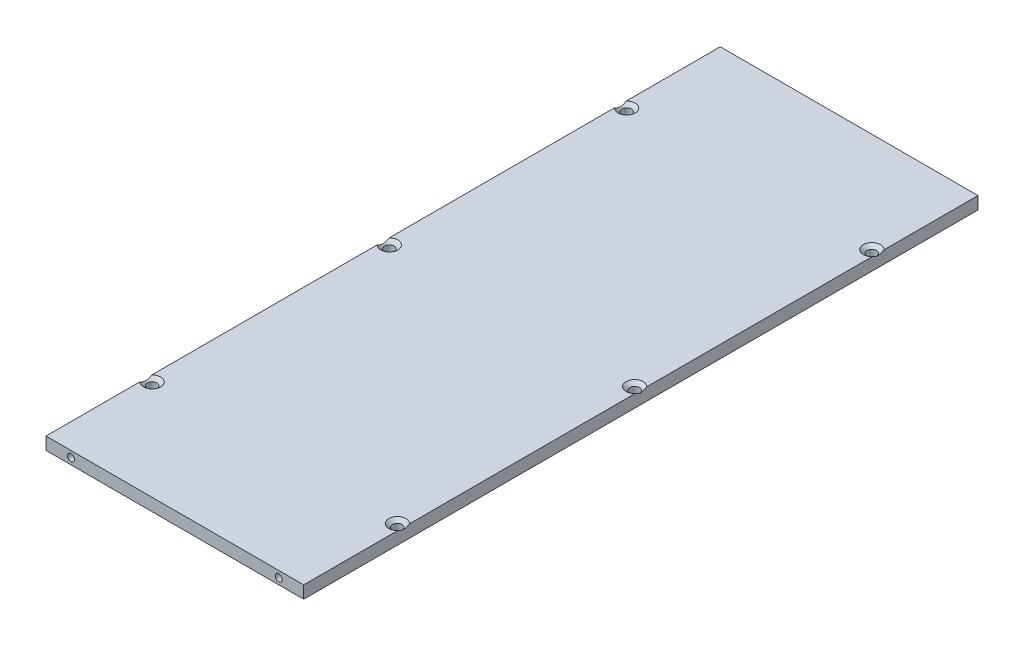
from build123d import *

# Parameters (mm, degrees)
SKETCH1_W                                         = 65.532
SKETCH1_H                                         = 171.45
EXTRUDE1_DEPTH                                    = 3.175
TAP_DRILL_FOR_2_TAP1_D                            = 1.778
TAP_DRILL_FOR_2_TAP1_DEPTH                        = 6.35
TAP_DRILL_FOR_2_TAP1_TIP                          = 0.53416509
TAP_DRILL_FOR_2_TAP2_D                            = 1.778
TAP_DRILL_FOR_2_TAP2_DEPTH                        = 6.35
TAP_DRILL_FOR_2_TAP2_TIP                          = 0.53416509
CSK_FOR_2_FLAT_HEAD_MACHINE_SCREW_100_D           = 2.4384
CSK_FOR_2_FLAT_HEAD_MACHINE_SCREW_100_CSINK_D     = 4.3688
CSK_FOR_2_FLAT_HEAD_MACHINE_SCREW_100_CSINK_ANGLE = 100


with BuildPart() as part:
    # Sketch1 → Extrude1 (new body)
    with BuildSketch(Plane(origin=(0, 0, 0), x_dir=(1, 0, 0), z_dir=(0, 1, 0))):
        Rectangle(SKETCH1_W, SKETCH1_H)
    extrude(amount=EXTRUDE1_DEPTH)

    # Tap Drill for #2 Tap1
    with Locations(Plane(origin=(-26.416, 1.5875, 85.725), x_dir=(1, 0, 0), z_dir=(0, 0, 1))):
        with Locations((0, 0), (52.832, 0)):
            Hole(TAP_DRILL_FOR_2_TAP1_D / 2, depth=TAP_DRILL_FOR_2_TAP1_DEPTH)
            with Locations((0, 0, -(TAP_DRILL_FOR_2_TAP1_DEPTH + TAP_DRILL_FOR_2_TAP1_TIP / 2))):  # 118° drill point
                Cone(0, TAP_DRILL_FOR_2_TAP1_D / 2, TAP_DRILL_FOR_2_TAP1_TIP, mode=Mode.SUBTRACT)

    # Tap Drill for #2 Tap2
    with Locations(Plane(origin=(26.416, 1.5875, -85.725), x_dir=(-1, 0, 0), z_dir=(0, 0, -1))):
        with Locations((0, 0), (52.832, 0)):
            Hole(TAP_DRILL_FOR_2_TAP2_D / 2, depth=TAP_DRILL_FOR_2_TAP2_DEPTH)
            with Locations((0, 0, -(TAP_DRILL_FOR_2_TAP2_DEPTH + TAP_DRILL_FOR_2_TAP2_TIP / 2))):  # 118° drill point
                Cone(0, TAP_DRILL_FOR_2_TAP2_D / 2, TAP_DRILL_FOR_2_TAP2_TIP, mode=Mode.SUBTRACT)

    # CSK for #2 Flat Head Machine Screw (100)1 (through all)
    with Locations(Plane(origin=(-31.1785, 3.175, -60.325), x_dir=(0, 0, 1), z_dir=(0, 1, 0))):
        with Locations((0, 0), (60.325, 0), (120.65, 0), (120.65, 62.357), (60.325, 62.357), (0, 62.357)):
            CounterSinkHole(CSK_FOR_2_FLAT_HEAD_MACHINE_SCREW_100_D / 2, CSK_FOR_2_FLAT_HEAD_MACHINE_SCREW_100_CSINK_D / 2, counter_sink_angle=CSK_FOR_2_FLAT_HEAD_MACHINE_SCREW_100_CSINK_ANGLE)


solid = part.part
